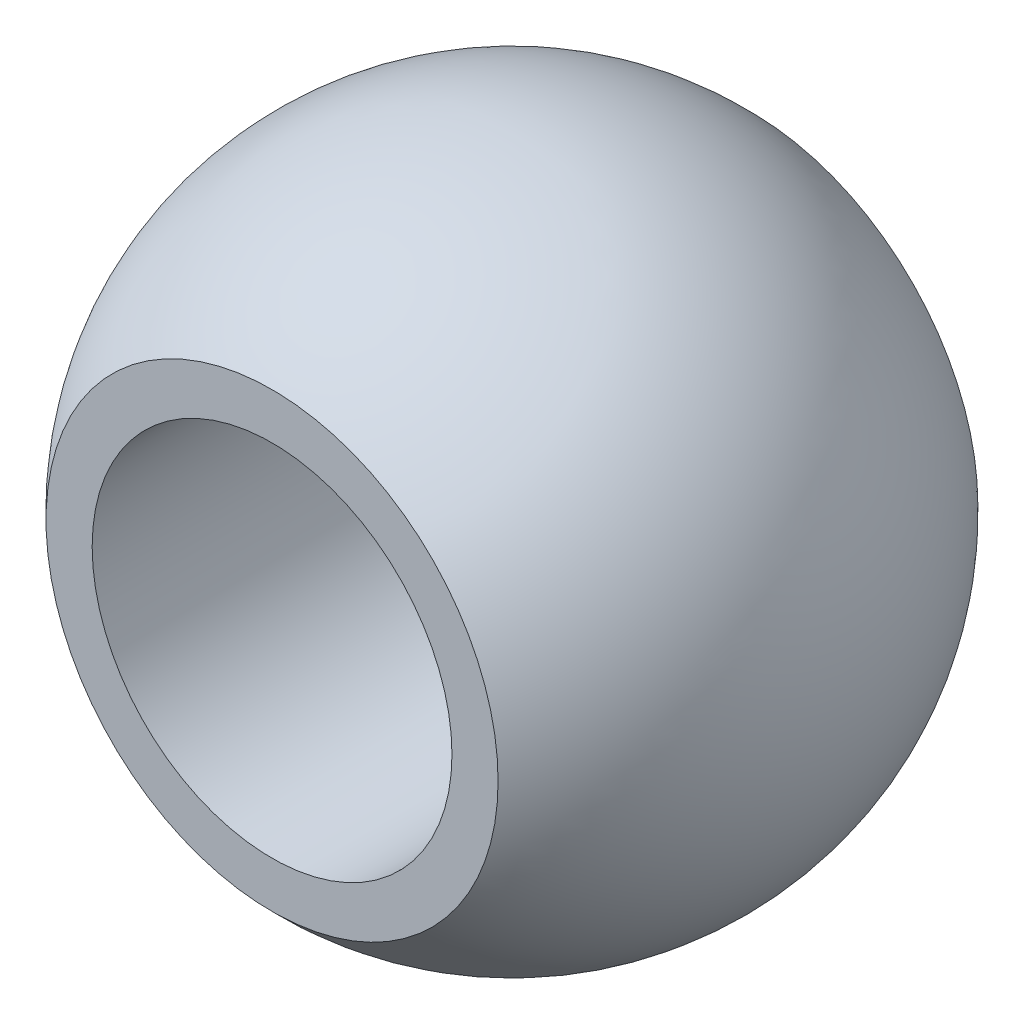
from build123d import *


with BuildPart() as part:
    # Sketch1 → Revolve1 (revolve)
    with BuildSketch(Plane(origin=(0, 0, 0), x_dir=(0, 0, -1), z_dir=(1, 0, 0))):
        with BuildLine():
            Line((-6.35, 5.983425441), (-6.35, 4.7625))
            Line((-6.35, 4.7625), (6.35, 4.7625))
            Line((6.35, 4.7625), (6.35, 5.983425441))
            ThreePointArc((6.35, 5.983425441), (0, 8.7249), (-6.35, 5.983425441))
        make_face()
    revolve(axis=Axis((0, 0, 31.258955331), (0, 0, -1)))


solid = part.part
